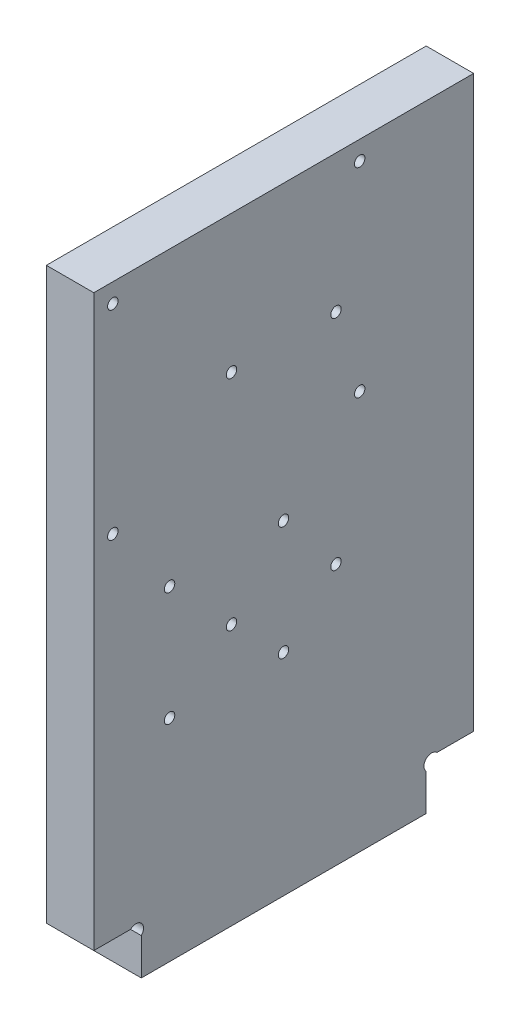
from build123d import *

# Parameters (mm, degrees)
ESQUISSE1_R             = 1.1
EXTRUSION1_DEPTH        = 10
ESQUISSE2_R             = 1.1
ENL_V_MAT_EXTRU_1_DEPTH = 2


with BuildPart() as part:
    # Esquisse1 → Extrusion1 (new body)
    with BuildSketch(Plane(origin=(0, 0, 0), x_dir=(0, 0, -1), z_dir=(1, 0, 0))):
        with BuildLine():
            Line((10, 7.7372583), (10, 0))
            Line((10, 0), (70, 0))
            Line((70, 0), (70, 7.7372583))
            ThreePointArc((70, 7.7372583), (70, 10), (72.2627417, 10))
            Line((72.2627417, 10), (80, 10))
            Line((80, 10), (80, 130))
            Line((80, 130), (0, 130))
            Line((0, 130), (0, 10))
            Line((0, 10), (7.7372583, 10))
            ThreePointArc((7.7372583, 10), (10, 10), (10, 7.7372583))
        make_face()
        with Locations((29, 101)):
            Circle(ESQUISSE1_R, mode=Mode.SUBTRACT)
        with Locations(Location((51, 101, 0), (0, 0, 180))):  # turned: the seam where the file's is
            Circle(ESQUISSE1_R, mode=Mode.SUBTRACT)
        with Locations(Location((29, 55, 0), (0, 0, 180))):  # turned: the seam where the file's is
            Circle(ESQUISSE1_R, mode=Mode.SUBTRACT)
        with Locations((51, 55)):
            Circle(ESQUISSE1_R, mode=Mode.SUBTRACT)
    extrude(amount=EXTRUSION1_DEPTH)

    # Esquisse2 → Enlèv. mat.-Extru.1 (cut)
    with BuildSketch(Plane(origin=(10, 0, 0), x_dir=(0, 0, -1), z_dir=(1, 0, 0))):
        with Locations((4, 126)):
            Circle(ESQUISSE2_R)
        with Locations(Location((56, 126, 0), (0, 0, 180))):  # turned: the seam where the file's is
            Circle(ESQUISSE2_R)
        with Locations(Location((4, 84, 0), (0, 0, 180))):  # turned: the seam where the file's is
            Circle(ESQUISSE2_R)
        with Locations((56, 84)):
            Circle(ESQUISSE2_R)
        with Locations((15.95, 68.45)):
            Circle(ESQUISSE2_R)
        with Locations((15.95, 44.45)):
            Circle(ESQUISSE2_R)
        with Locations((39.95, 44.45)):
            Circle(ESQUISSE2_R)
        with Locations((39.95, 68.45)):
            Circle(ESQUISSE2_R)
    extrude(amount=-ENL_V_MAT_EXTRU_1_DEPTH, mode=Mode.SUBTRACT)


solid = part.part
